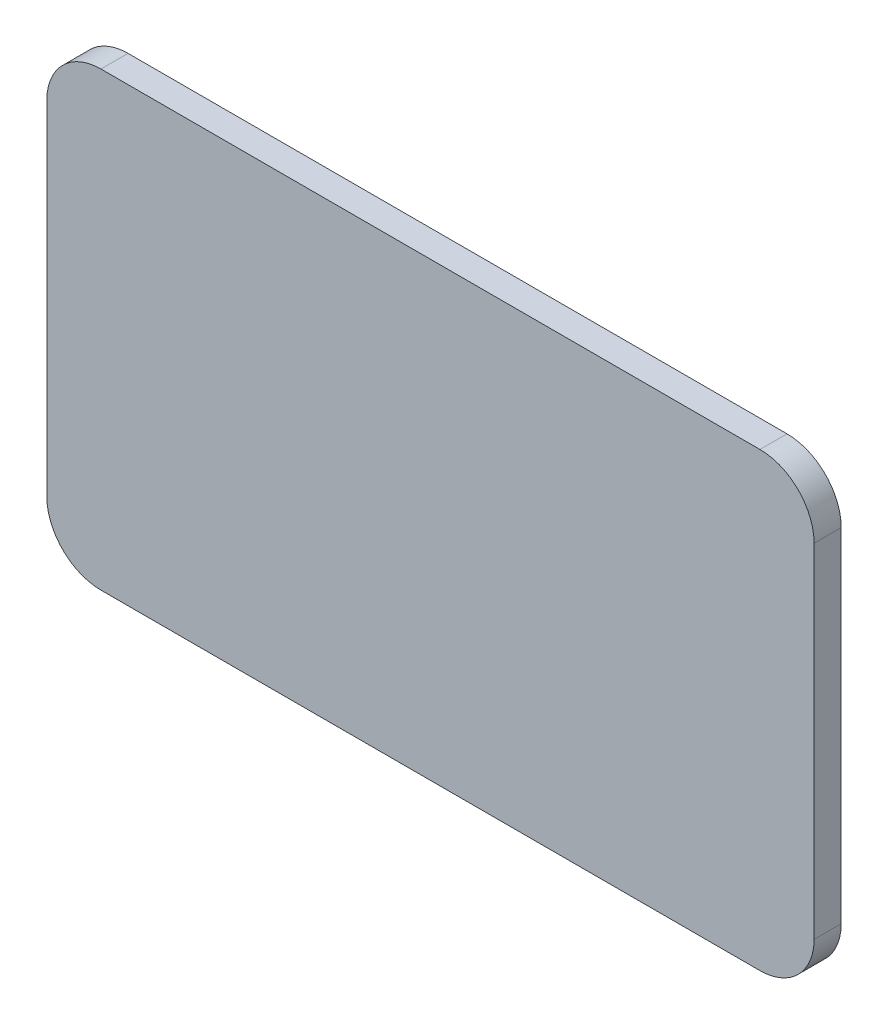
from build123d import *

# Parameters (mm, degrees)
BOSS_EXTRUDE6_DEPTH = 3


with BuildPart() as part:
    # Sketch1 → Boss-Extrude6 (new body)
    with BuildSketch(Plane.XY):
        with BuildLine():
            Line((-36.5, -25), (36.5, -25))
            ThreePointArc((36.5, -25), (40.742640687, -23.242640687), (42.5, -19))
            Line((42.5, -19), (42.5, 19))
            ThreePointArc((42.5, 19), (40.742640687, 23.242640687), (36.5, 25))
            Line((36.5, 25), (-36.5, 25))
            ThreePointArc((-36.5, 25), (-40.742640687, 23.242640687), (-42.5, 19))
            Line((-42.5, 19), (-42.5, -19))
            ThreePointArc((-42.5, -19), (-40.742640687, -23.242640687), (-36.5, -25))
        make_face()
    extrude(amount=BOSS_EXTRUDE6_DEPTH)


solid = part.part
